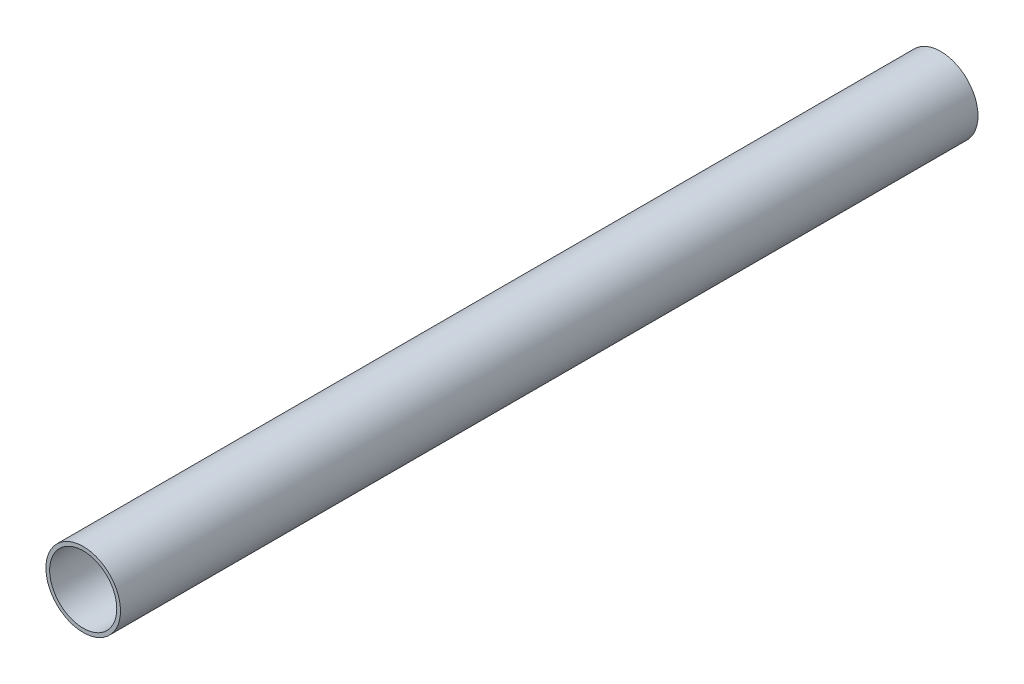
from build123d import *

# Parameters (mm, degrees)
SKETCH1_R           = 10
SKETCH1_R_2         = 9
BOSS_EXTRUDE1_DEPTH = 230


with BuildPart() as part:
    # Sketch1 → Boss-Extrude1 (new body)
    with BuildSketch(Plane.XY):
        Circle(SKETCH1_R)
        Circle(SKETCH1_R_2, mode=Mode.SUBTRACT)
    extrude(amount=BOSS_EXTRUDE1_DEPTH)


solid = part.part
